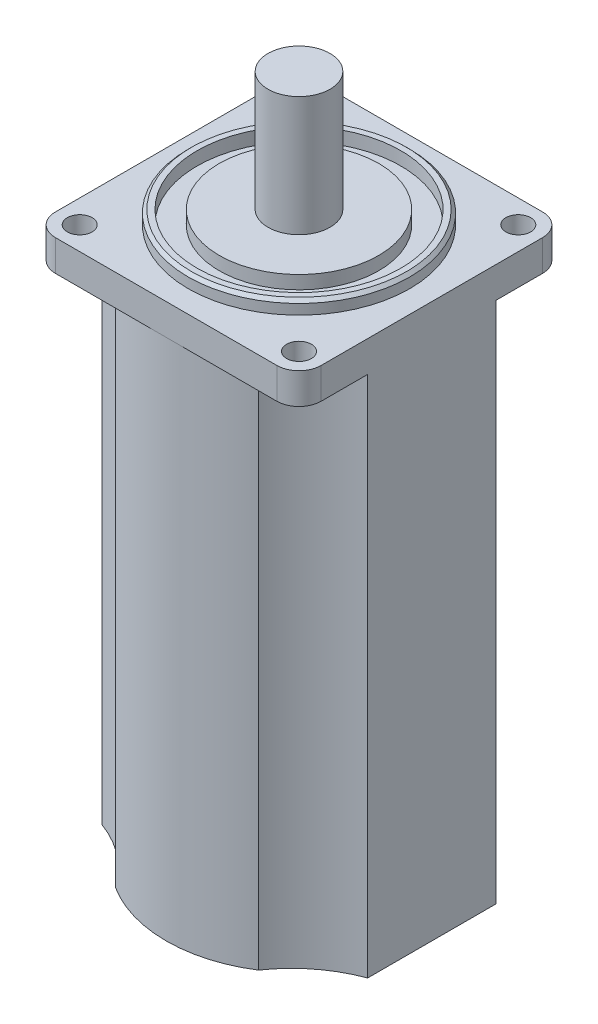
from build123d import *

# Parameters (mm, degrees)
SKETCH1_R           = 2.8
BOSS_EXTRUDE1_DEPTH = 7
SKETCH2_R           = 25
SKETCH2_R_2         = 23
SKETCH2_R_3         = 18
BOSS_EXTRUDE3_DEPTH = 3
CHAMFER2_SIZE       = 0.71
BOSS_EXTRUDE4_DEPTH = 118
SKETCH5_R           = 7
BOSS_EXTRUDE5_DEPTH = 27


with BuildPart() as part:
    # Sketch1 → Boss-Extrude1 (new body)
    with BuildSketch(Plane(origin=(0, 0, 0), x_dir=(1, 0, 0), z_dir=(0, 1, 0))):
        with BuildLine():
            Line((-25, -30), (25, -30))
            ThreePointArc((25, -30), (28.535533906, -28.535533906), (30, -25))
            Line((30, -25), (30, 25))
            ThreePointArc((30, 25), (28.535533906, 28.535533906), (25, 30))
            Line((25, 30), (-25, 30))
            ThreePointArc((-25, 30), (-28.535533906, 28.535533906), (-30, 25))
            Line((-30, 25), (-30, -25))
            ThreePointArc((-30, -25), (-28.535533906, -28.535533906), (-25, -30))
        make_face()
        with Locations((-24.748737342, 24.748737342)):
            Circle(SKETCH1_R, mode=Mode.SUBTRACT)
        with Locations((24.748737342, 24.748737342)):
            Circle(SKETCH1_R, mode=Mode.SUBTRACT)
        with Locations((24.748737342, -24.748737342)):
            Circle(SKETCH1_R, mode=Mode.SUBTRACT)
        with Locations((-24.748737342, -24.748737342)):
            Circle(SKETCH1_R, mode=Mode.SUBTRACT)
    extrude(amount=BOSS_EXTRUDE1_DEPTH)

    # Sketch2 → Boss-Extrude3 (add)
    with BuildSketch(Plane(origin=(0, 7, 0), x_dir=(1, 0, 0), z_dir=(0, 1, 0))):
        Circle(SKETCH2_R)
        Circle(SKETCH2_R_2, mode=Mode.SUBTRACT)
        Circle(SKETCH2_R_3)
    extrude(amount=BOSS_EXTRUDE3_DEPTH)

    # Chamfer2
    chamfer2_edges = [part.edges().sort_by_distance(p)[0] for p in [
        (-25, 10, 0),
    ]]
    chamfer(chamfer2_edges, length=CHAMFER2_SIZE)

    # Sketch3 → Boss-Extrude4 (add)
    with BuildSketch(Plane.XZ):
        with BuildLine():
            Line((-30, 14.5), (-30, -14.5))
            ThreePointArc((-30, -14.5), (-22.221450139, -18.82296717), (-16.12, -25.30109879))
            ThreePointArc((-16.12, -25.30109879), (0, -30), (16.12, -25.30109879))
            ThreePointArc((16.12, -25.30109879), (22.221450139, -18.82296717), (30, -14.5))
            Line((30, -14.5), (30, 14.5))
            ThreePointArc((30, 14.5), (22.221450139, 18.82296717), (16.12, 25.30109879))
            ThreePointArc((16.12, 25.30109879), (0, 30), (-16.12, 25.30109879))
            ThreePointArc((-16.12, 25.30109879), (-22.221450139, 18.82296717), (-30, 14.5))
        make_face()
    extrude(amount=BOSS_EXTRUDE4_DEPTH)

    # Sketch5 → Boss-Extrude5 (add)
    with BuildSketch(Plane(origin=(0, 10, 0), x_dir=(1, 0, 0), z_dir=(0, 1, 0))):
        Circle(SKETCH5_R)
    extrude(amount=BOSS_EXTRUDE5_DEPTH)


solid = part.part
